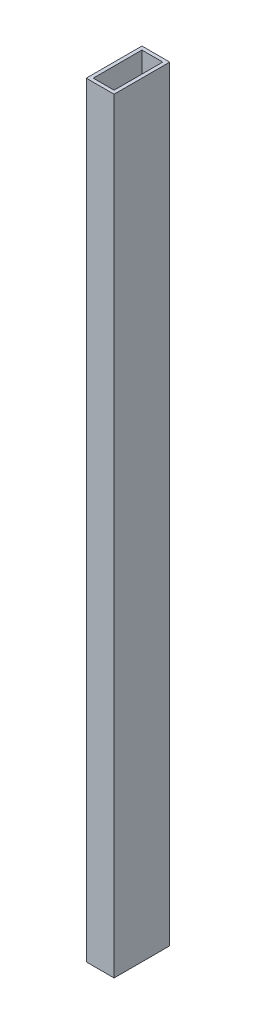
from build123d import *

# Parameters (mm, degrees)
SKETCH1_W           = 25.4
SKETCH1_H           = 50.8
SKETCH1_W_2         = 19.05
SKETCH1_H_2         = 44.45
BOSS_EXTRUDE1_DEPTH = 698.5


with BuildPart() as part:
    # Sketch1 → Boss-Extrude1 (new body)
    with BuildSketch(Plane(origin=(0, 0, 0), x_dir=(1, 0, 0), z_dir=(0, 1, 0))):
        with Locations((12.7, 25.4)):
            Rectangle(SKETCH1_W, SKETCH1_H)
        with Locations((12.7, 25.4)):
            Rectangle(SKETCH1_W_2, SKETCH1_H_2, mode=Mode.SUBTRACT)
    extrude(amount=BOSS_EXTRUDE1_DEPTH)


solid = part.part
